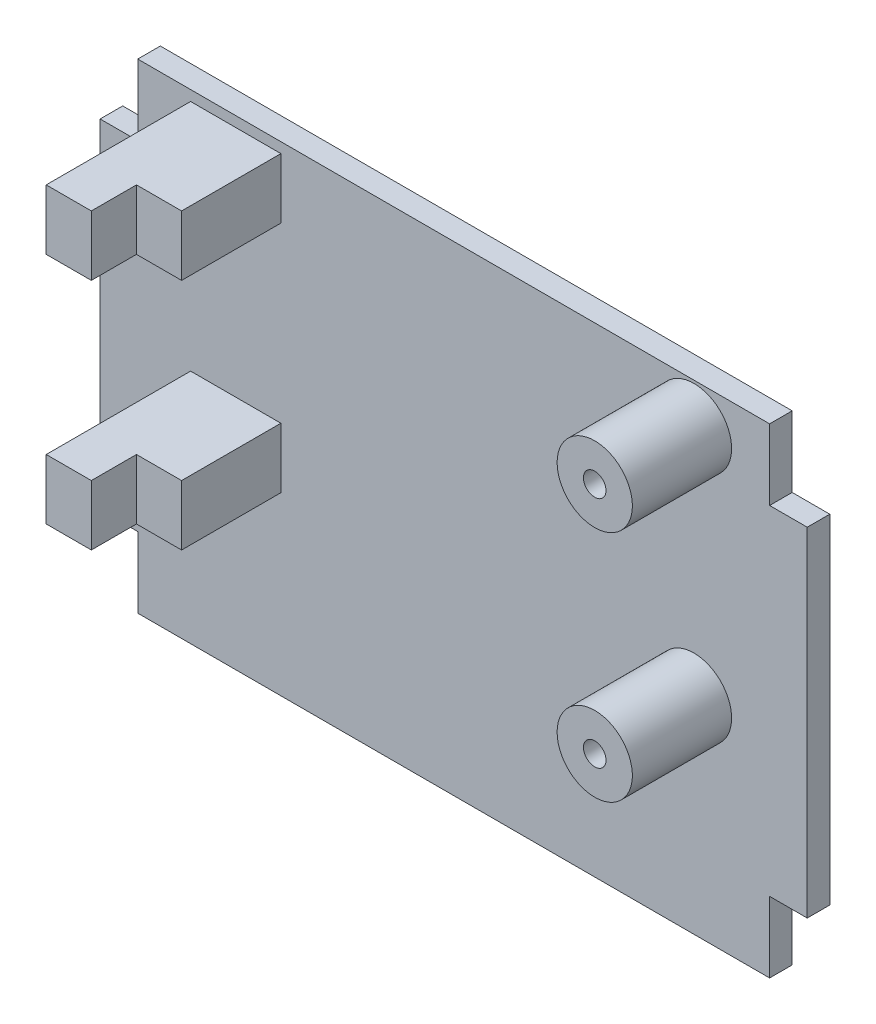
from build123d import *

# Parameters (mm, degrees)
ESQUISSE1_W             = 47
ESQUISSE1_H             = 31.9
BOSS_EXTRU_1_DEPTH      = 1.5
ESQUISSE2_W             = 2.5
ESQUISSE2_H             = 4.7
ENL_V_MAT_EXTRU_1_DEPTH = 2.5
ESQUISSE3_R             = 2.5
ESQUISSE3_W             = 6
ESQUISSE3_H             = 4
BOSS_EXTRU_2_DEPTH      = 6.599064
ESQUISSE4_W             = 3
ESQUISSE4_H             = 4
BOSS_EXTRU_3_DEPTH      = 3
ESQUISSE4_3_R           = 0.75
ENL_V_MAT_EXTRU_2_DEPTH = 5


with BuildPart() as part:
    # Esquisse1 → Boss.-Extru.1 (new body)
    with BuildSketch(Plane.XY):
        with Locations((23.5, 15.95)):
            Rectangle(ESQUISSE1_W, ESQUISSE1_H)
    extrude(amount=BOSS_EXTRU_1_DEPTH)

    # Esquisse2 → Enl_v. mat.-Extru.1 (cut, through all)
    with BuildSketch(Plane.XY.offset(1.5)):
        with Locations((45.75, 29.55)):
            Rectangle(ESQUISSE2_W, ESQUISSE2_H)
        with Locations((45.75, 2.35)):
            Rectangle(ESQUISSE2_W, ESQUISSE2_H)
        with Locations((1.25, 2.35)):
            Rectangle(ESQUISSE2_W, ESQUISSE2_H)
        with Locations((1.25, 29.55)):
            Rectangle(ESQUISSE2_W, ESQUISSE2_H)
    extrude(amount=-ENL_V_MAT_EXTRU_1_DEPTH, mode=Mode.SUBTRACT)

    # Esquisse3 → Boss.-Extru.2 (add)
    with BuildSketch(Plane.XY.offset(1.5)):
        with Locations((39.474011, 29.2125)):
            Circle(ESQUISSE3_R)
        with Locations((39.474011, 13.6925)):
            Circle(ESQUISSE3_R)
        with Locations((9.014011, 29.2125)):
            Rectangle(ESQUISSE3_W, ESQUISSE3_H)
        with Locations((9.014011, 13.6925)):
            Rectangle(ESQUISSE3_W, ESQUISSE3_H)
    extrude(amount=BOSS_EXTRU_2_DEPTH)

    # Esquisse4 → Boss.-Extru.3 (add)
    with BuildSketch(Plane.XY.offset(8.099064)):
        with Locations((7.514011, 13.6925)):
            Rectangle(ESQUISSE4_W, ESQUISSE4_H)
        with Locations((7.514011, 29.2125)):
            Rectangle(ESQUISSE4_W, ESQUISSE4_H)
    extrude(amount=BOSS_EXTRU_3_DEPTH)

    # Esquisse4_3 → Enl_v. mat.-Extru.2 (cut)
    with BuildSketch(Plane.XY.offset(8.099064)):
        with Locations((39.474011, 29.2125)):
            Circle(ESQUISSE4_3_R)
        with Locations((39.474011, 13.6925)):
            Circle(ESQUISSE4_3_R)
    extrude(amount=-ENL_V_MAT_EXTRU_2_DEPTH, mode=Mode.SUBTRACT)


solid = part.part
